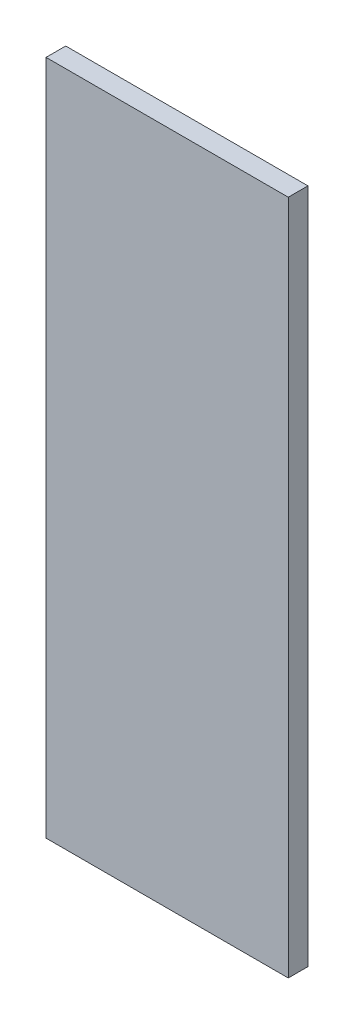
from build123d import *

# Parameters (mm, degrees)
SKETCH1_W           = 197
SKETCH1_H           = 550
BOSS_EXTRUDE1_DEPTH = 16


with BuildPart() as part:
    # Sketch1 → Boss-Extrude1 (new body)
    with BuildSketch(Plane.XY):
        Rectangle(SKETCH1_W, SKETCH1_H)
    extrude(amount=BOSS_EXTRUDE1_DEPTH)


solid = part.part
